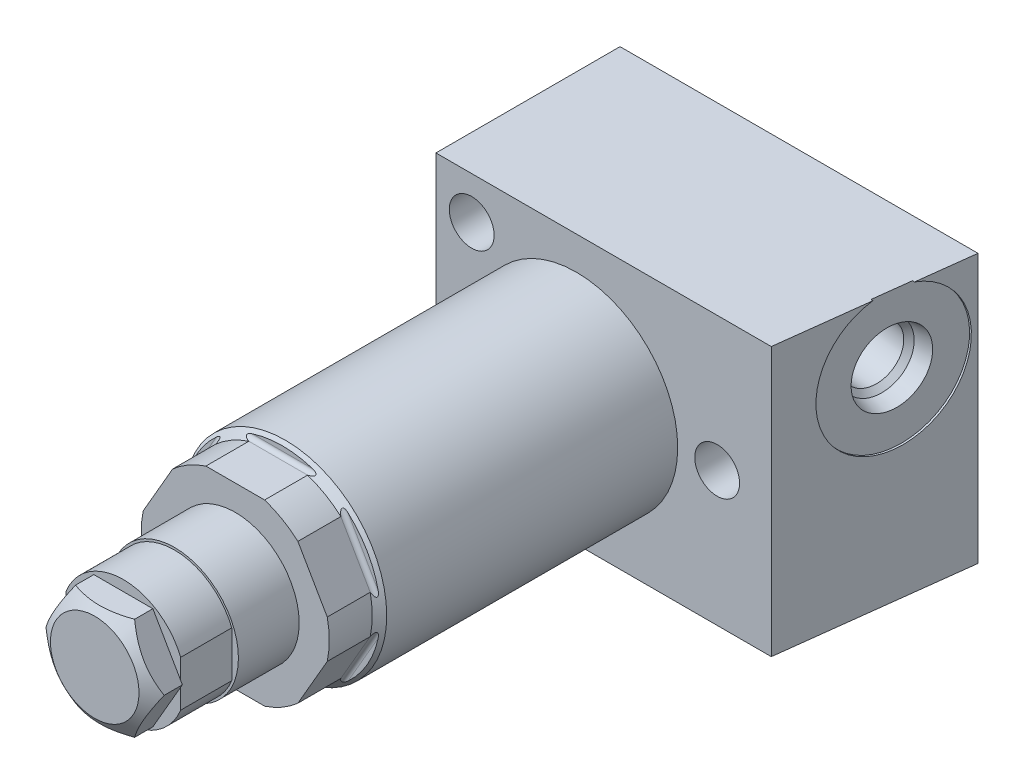
from build123d import *

# Parameters (mm, degrees)
SKETCH1_R           = 12.573
EXTRUDE1_DEPTH      = 55.8292
CUT_EXTRUDE1_DEPTH  = 15.0876
SKETCH12_W          = 13.8938
SKETCH12_H          = 7.9375
CUT_EXTRUDE10_DEPTH = 6.35
EXTRUDE2_DEPTH      = 3.556
EXTRUDE3_DEPTH      = 16.6751
EXTRUDE3_DEPTH_BACK = 16.6751
SKETCH19_R          = 8.6614
CUT_EXTRUDE11_DEPTH = 0.254
SKETCH22_R          = 1.27
CIRPATTERN2_COUNT   = 6
SKETCH23_W          = 2.7813
SKETCH23_H          = 22.86
HOLE1_AT_2_COUNT    = 2
HOLE1_AT_2_PITCH    = 32.55265427
HOLE1_AT_3_COUNT    = 2
HOLE1_AT_3_PITCH    = 22.86
SKETCH27_W          = 6.35
SKETCH27_H          = 0.2794


with BuildPart() as part:
    # Sketch1 → Extrude1 (new body)
    with BuildSketch(Plane.XY):
        Circle(SKETCH1_R)
    extrude(amount=EXTRUDE1_DEPTH)

    # Sketch2 → Cut-Extrude1 (cut, symmetric)
    with BuildSketch(Plane(origin=(0, 0, 0), x_dir=(0, 0, 1), z_dir=(1, 0, 0))):
        with BuildLine():
            Line((49.9872, 12.573), (49.9872, 11.5951))
            ThreePointArc((49.9872, 11.5951), (50.135989755, 11.235889755), (50.4952, 11.0871))
            Line((50.4952, 11.0871), (55.8292, 11.0871))
            Line((55.8292, 11.0871), (55.8292, 12.573))
            Line((55.8292, 12.573), (49.9872, 12.573))
        make_face()
    cut_extrude1 = extrude(amount=CUT_EXTRUDE1_DEPTH, both=True, mode=Mode.SUBTRACT)

    # Sketch10 → Cut-Revolve1 (revolve, cut)
    with BuildSketch(Plane(origin=(0, 0, 0), x_dir=(0, 0, -1), z_dir=(1, 0, 0)), mode=Mode.PRIVATE) as cut_revolve1_sk:
        Polygon((-55.8292, 11.6713), (-50.4952, 11.6713), (-49.5935, 12.573), (-55.8292, 12.573), align=None)
    revolve(cut_revolve1_sk.sketch.rotate(Axis((0, 0, 42.932985), (0, 0, -1)), 90), axis=Axis((0, 0, 42.932985), (0, 0, -1)), mode=Mode.SUBTRACT)  # turned: the seam where the file's is

    # Sketch12 → Revolve1 (revolve)
    with BuildSketch(Plane(origin=(0, 0, 0), x_dir=(0, 0, -1), z_dir=(1, 0, 0)), mode=Mode.PRIVATE) as revolve1_sk:
        with Locations((-62.7761, 3.96875)):
            Rectangle(SKETCH12_W, SKETCH12_H)
    revolve(revolve1_sk.sketch.rotate(Axis((0, 0, 54.27599), (0, 0, -1)), 90), axis=Axis((0, 0, 54.27599), (0, 0, -1)))  # turned: the seam where the file's is

    # Sketch15 → Cut-Extrude10 (cut)
    with BuildSketch(Plane.YX.offset(-69.723)):
        with BuildLine():
            Line((-3.524679028, 7.112), (3.524679028, 7.112))
            ThreePointArc((3.524679028, 7.112), (0, 7.9375), (-3.524679028, 7.112))
        make_face()
        with BuildLine():
            Line((-3.524679028, -7.112), (3.524679028, -7.112))
            ThreePointArc((3.524679028, -7.112), (0, -7.9375), (-3.524679028, -7.112))
        make_face()
    extrude(amount=CUT_EXTRUDE10_DEPTH, mode=Mode.SUBTRACT)

    # Sketch16 → Extrude2 (add)
    with BuildSketch(Plane.XY.offset(69.723)):
        Polygon((-3.666174209, 6.35), (3.666174209, 6.35), (7.332348419, 0), (3.666174209, -6.35), (-3.666174209, -6.35), (-7.332348419, 0), align=None)
    extrude(amount=EXTRUDE2_DEPTH)

    # Sketch17 → Cut-Revolve4 (revolve, cut)
    with BuildSketch(Plane(origin=(0, 0, 0), x_dir=(1, 0, 0), z_dir=(0, 1, 0))):
        Polygon((5.4991, -73.279), (7.332348419, -71.995345638), (7.332348419, -73.279), align=None)
    revolve(axis=Axis((0, 0, 57.341182718), (0, 0, -1)), mode=Mode.SUBTRACT)

    # Sketch18 → Extrude3 (add, two sides)
    with BuildSketch(Plane(origin=(0, 0, 0), x_dir=(-1, 0, 0), z_dir=(0, 1, 0))) as extrude3_sk:
        Polygon((-27.0002, -9.398), (17.4498, -9.398), (17.4498, 13.462), (-24.193344938, 13.462), align=None)
    extrude(amount=EXTRUDE3_DEPTH)
    extrude(extrude3_sk.sketch, amount=-EXTRUDE3_DEPTH_BACK)

    # Sketch19 → Cut-Extrude11 (cut)
    with BuildSketch(Plane(origin=(25.462398347, 0, 3.126389401), x_dir=(0.121869343, 0, -0.992546152), z_dir=(0.992546152, 0, 0.121869343))):
        with Locations((3.220445379, 8.3312)):
            Circle(SKETCH19_R)
    extrude(amount=-CUT_EXTRUDE11_DEPTH, mode=Mode.SUBTRACT)

    # S2D0001 → Cut-Revolve5 (revolve, cut)
    with BuildSketch(Plane(origin=(25.602765188, 8.3312, -0.10100608), x_dir=(-0.121869343, 0, 0.992546152), z_dir=(0, 1, 0))):
        Polygon((0, 0), (4.5466, 0), (4.106586662, -2.0701), (3.4544, -2.722286662), (3.4544, -12.192), (0, -12.192), align=None)
    revolve(axis=Axis((12.896586373, 8.3312, -1.661128667), (0.992546152, 0, 0.121869343)), mode=Mode.SUBTRACT)

    # Sketch21 → Cut-Revolve6 (revolve, cut)
    with BuildSketch(Plane(origin=(17.4752, -9.73455, -8.356503206), x_dir=(-1, 0, 0), z_dir=(0, 1, 0))):
        Polygon((0, -1.041496794), (6.35, -1.041496794), (6.35, 1.498503206), (3.4544, 1.498503206), (3.4544, 13.690503206), (0, 15.766116128), align=None)
    revolve(axis=Axis((17.4752, -9.73455, -10.238380646), (0, 0, 1)), mode=Mode.SUBTRACT)

    # CirPattern2: Cut-Extrude1 ×6 about axis
    cirpattern2_axis = Axis((0, 0, 0), (0, 0, 1))
    for i in range(1, CIRPATTERN2_COUNT):
        add(cut_extrude1.rotate(cirpattern2_axis, i * 360 / CIRPATTERN2_COUNT), mode=Mode.SUBTRACT)

    # Sketch23 → Hole1 (revolve, cut)
    with BuildSketch(Plane(origin=(-13.0048, -11.43, 13.462), x_dir=(0, -1, 0), z_dir=(1, 0, 0))):
        with Locations((1.39065, 11.43)):
            Rectangle(SKETCH23_W, SKETCH23_H)
    hole1 = revolve(axis=Axis((-13.0048, -11.43, -96.538), (0, 0, 1)), mode=Mode.SUBTRACT)

    # Hole1 at 2: Hole1 ×2
    with Locations(*[Vector(0.936329178, 0.351123442, 0) * (i * HOLE1_AT_2_PITCH) for i in range(1, HOLE1_AT_2_COUNT)]):
        add(hole1, mode=Mode.SUBTRACT)

    # Hole1 at 3: Hole1 ×2
    with Locations(*[(0, i * HOLE1_AT_3_PITCH, 0) for i in range(1, HOLE1_AT_3_COUNT)]):
        add(hole1, mode=Mode.SUBTRACT)

    # Sketch27 → Cut-Revolve7 (revolve, cut)
    with BuildSketch(Plane(origin=(0, 0, 0), x_dir=(0, 0, -1), z_dir=(1, 0, 0)), mode=Mode.PRIVATE) as cut_revolve7_sk:
        with Locations((-66.548, 7.7978)):
            Rectangle(SKETCH27_W, SKETCH27_H)
    revolve(cut_revolve7_sk.sketch.rotate(Axis((0, 0, -9.398), (0, 0, 1)), 270), axis=Axis((0, 0, -9.398), (0, 0, 1)), mode=Mode.SUBTRACT)  # turned: the seam where the file's is


with BuildPart() as body_2:
    # Sketch22 → Revolve2 (revolve)
    with BuildSketch(Plane(origin=(17.4752, -9.73455, -8.356503206), x_dir=(-1, 0, 0), z_dir=(0, 1, 0)), mode=Mode.PRIVATE) as revolve2_sk:
        with Locations((-5.08, 0.228503206)):
            Circle(SKETCH22_R)
    revolve(revolve2_sk.sketch.rotate(Axis((17.4752, -9.73455, -9.525), (0, 0, 1)), 180), axis=Axis((17.4752, -9.73455, -9.525), (0, 0, 1)))  # turned: the seam where the file's is


solid = Compound([part.part, body_2.part])
